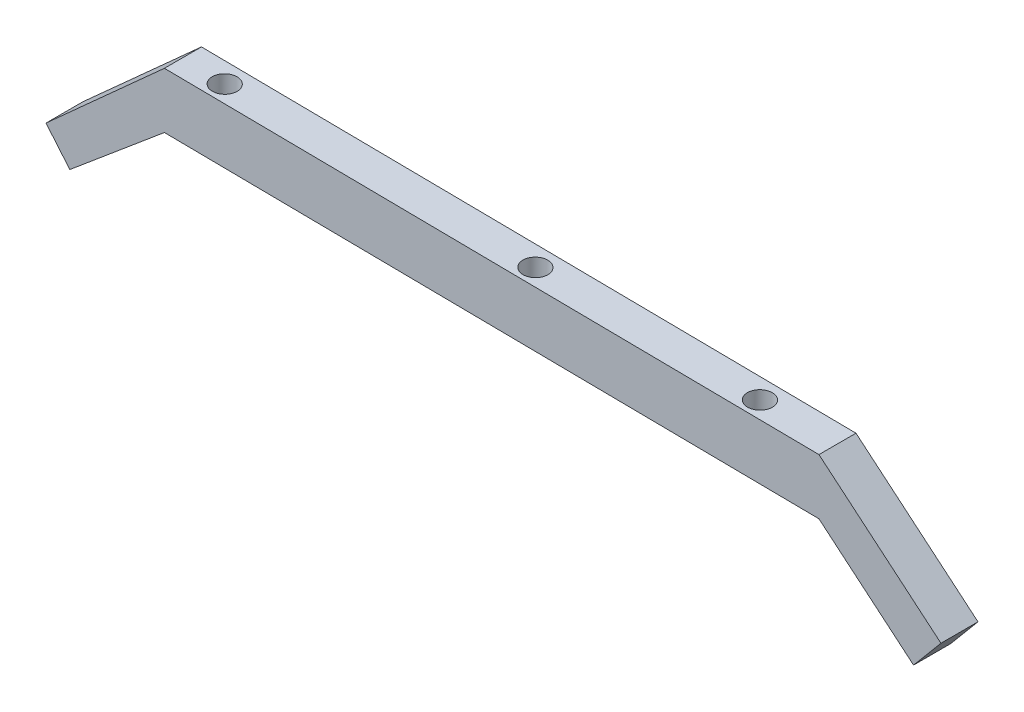
from build123d import *

# Parameters (mm, degrees)
BOSS_EXTRUDE1_DEPTH = 6
SKETCH2_R           = 2.017088466
CUT_EXTRUDE1_DEPTH  = 25


with BuildPart() as part:
    # Sketch1 → Boss-Extrude1 (new body)
    with BuildSketch(Plane.XY):
        Polygon((-57.233453794, -0.097651304), (48.766546206, -1.275016763), (64.087435069, -14.130768957), (68.523900043, -8.843595885), (48.766546206, 7.734792432), (-57.233453794, 8.912157892), (-76.411068314, -8.357136839), (-72.554342656, -12.953403497), align=None)
    extrude(amount=BOSS_EXTRUDE1_DEPTH)

    # Sketch2 → Cut-Extrude1 (cut)
    with BuildSketch(Plane(origin=(0.091917058, 8.275432311, 0), x_dir=(0.999938321, -0.011106536, 0), z_dir=(0.011106536, 0.999938321, 0))):
        with Locations((0, -3.248787457)):
            Circle(SKETCH2_R)
        with Locations((36.371042159, -3.248787457)):
            Circle(SKETCH2_R)
        with Locations((-50.316115852, -3.248787457)):
            Circle(SKETCH2_R)
    extrude(amount=-CUT_EXTRUDE1_DEPTH, mode=Mode.SUBTRACT)


solid = part.part
